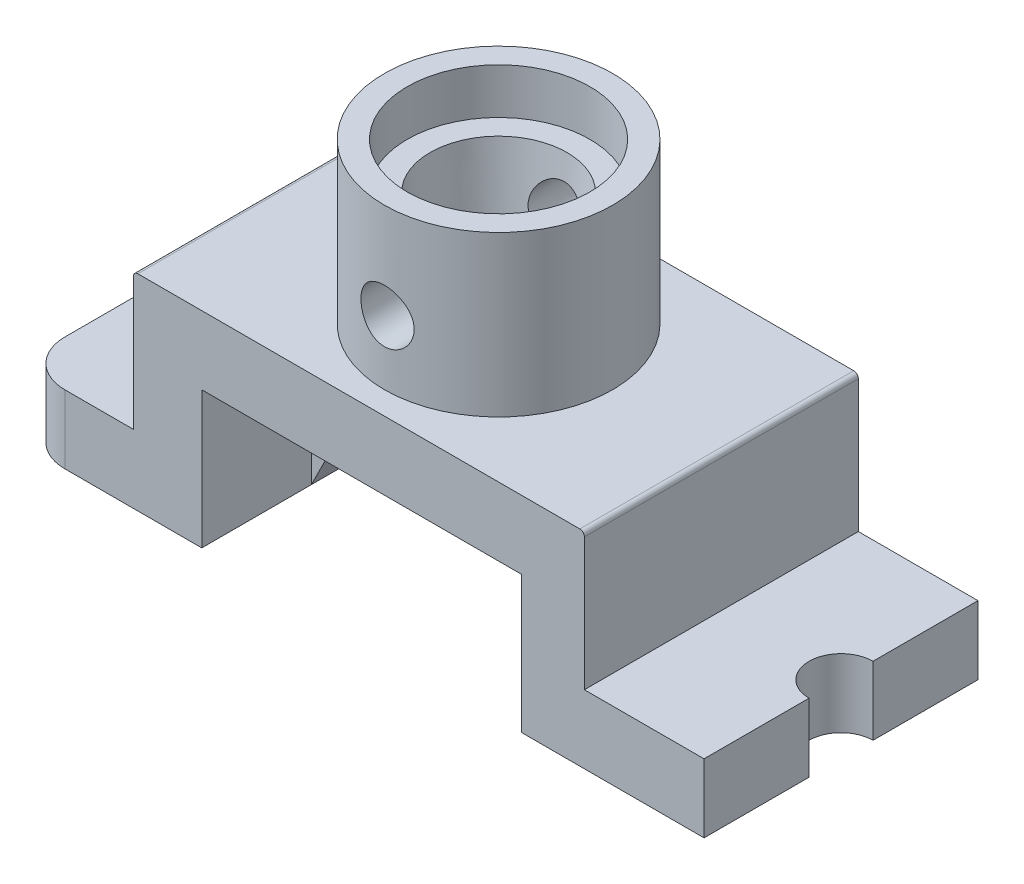
from build123d import *

# Parameters (mm, degrees)
BOSS_EXTRUDE1_DEPTH     = 600
SKETCH2_R               = 250
BOSS_EXTRUDE3_DEPTH     = 350
SKETCH6_R               = 200
CUT_EXTRUDE1_DEPTH      = 100
SKETCH8_R               = 100
SKETCH7_R               = 150
FILLET2_R               = 100
FILLET3_R               = 10
SKETCH11_R              = 58.235787107
CUT_EXTRUDE5_DEPTH      = 1362.628038628
CUT_EXTRUDE5_DEPTH_BACK = 1362.628038628
CUT_EXTRUDE6_REACH      = 1281.27
SKETCH12_R              = 70
RIB1_REACH              = 1260.583
SKETCH13_WALL_W         = 2854.575996278
SKETCH13_WALL_H         = 120
RIB2_REACH              = 1260.583
SKETCH14_WALL_W         = 2854.575996278
SKETCH14_WALL_H         = 120


with BuildPart() as part:
    # Sketch1 → Boss-Extrude1 (new body)
    with BuildSketch(Plane.XY):
        Polygon((-175.862068966, 0), (-575.862068966, 0), (-575.862068966, 150), (-325.862068966, 150), (-325.862068966, 450), (662.068965517, 450), (662.068965517, 150), (924.137931034, 150), (924.137931034, 0), (524.137931034, 0), (524.137931034, 300), (-175.862068966, 300), align=None)
    extrude(amount=BOSS_EXTRUDE1_DEPTH)

    # Sketch2 → Boss-Extrude3 (add)
    with BuildSketch(Plane(origin=(0, 450, 0), x_dir=(1, 0, 0), z_dir=(0, 1, 0))):
        with Locations(Location((174.137931034, -300, 0), (0, 0, 270))):
            Circle(SKETCH2_R)
    extrude(amount=BOSS_EXTRUDE3_DEPTH)

    # Sketch6 → Cut-Extrude1 (cut)
    with BuildSketch(Plane(origin=(0, 800, 0), x_dir=(1, 0, 0), z_dir=(0, 1, 0))):
        with Locations(Location((174.137931034, -300, 0), (0, 0, 270))):
            Circle(SKETCH6_R)
    extrude(amount=-CUT_EXTRUDE1_DEPTH, mode=Mode.SUBTRACT)

    # Sketch8 → Cut-Loft1 section 0
    with BuildSketch(Plane.XZ.offset(-300)):
        with Locations((174.137931034, 300)):
            Circle(SKETCH8_R)
    # Sketch7 → Cut-Loft1 section 1
    with BuildSketch(Plane(origin=(0, 700, 0), x_dir=(1, 0, 0), z_dir=(0, 1, 0))):
        with Locations((174.137931034, -300)):
            Circle(SKETCH7_R)
    loft(mode=Mode.SUBTRACT)

    # Fillet2
    fillet2_edges = [part.edges().sort_by_distance(p)[0] for p in [
        (-575.862068966, 75, 0),
        (-575.862068966, 75, 600),
    ]]
    fillet(fillet2_edges, radius=FILLET2_R)

    # Fillet3
    fillet3_edges = [part.edges().sort_by_distance(p)[0] for p in [
        (-325.862068966, 450, 300),
        (662.068965517, 450, 300),
    ]]
    fillet(fillet3_edges, radius=FILLET3_R)

    # Sketch11 → Cut-Extrude5 (cut, two sides)
    with BuildSketch(Plane.XY) as cut_extrude5_sk:
        with Locations(Location((174.137931034, 590, 0), (0, 0, 90.000000003))):
            Circle(SKETCH11_R)
    extrude(amount=CUT_EXTRUDE5_DEPTH, mode=Mode.SUBTRACT)
    extrude(cut_extrude5_sk.sketch, amount=-CUT_EXTRUDE5_DEPTH_BACK, mode=Mode.SUBTRACT)

    # Sketch12 → Cut-Extrude6 (cut, up to next)
    with BuildSketch(Plane(origin=(0, 150, 0), x_dir=(1, 0, 0), z_dir=(0, 1, 0)), mode=Mode.PRIVATE) as cut_extrude6_sk1:
        with Locations((924.137931034, -300)):
            Circle(SKETCH12_R)
    cut_extrude6_tool1 = extrude(cut_extrude6_sk1.sketch, amount=-CUT_EXTRUDE6_REACH, mode=Mode.PRIVATE) & part.part
    add(cut_extrude6_tool1.solids().sort_by_distance((924.137931, 150, 300))[0], mode=Mode.SUBTRACT)

    # Sketch13 wall → Rib1 (add, up to next)
    with BuildSketch(Plane(origin=(-100.862068966, 150, 300), x_dir=(0.4472135955, 0.894427191, 0), z_dir=(-0.894427191, 0.4472135955, 0)), mode=Mode.PRIVATE) as rib1_sk1:
        Rectangle(SKETCH13_WALL_W, SKETCH13_WALL_H)
    rib1_tool1 = extrude(rib1_sk1.sketch, amount=RIB1_REACH, mode=Mode.PRIVATE) - part.part
    add(rib1_tool1.solids().sort_by_distance((-100.862068966, 150, 300))[0])

    # Sketch14 wall → Rib2 (add, up to next)
    with BuildSketch(Plane(origin=(449.137931034, 150, 300), x_dir=(-0.4472135955, 0.894427191, 0), z_dir=(-0.894427191, -0.4472135955, 0)), mode=Mode.PRIVATE) as rib2_sk1:
        Rectangle(SKETCH14_WALL_W, SKETCH14_WALL_H)
    rib2_tool1 = extrude(rib2_sk1.sketch, amount=-RIB2_REACH, mode=Mode.PRIVATE) - part.part
    add(rib2_tool1.solids().sort_by_distance((449.137931034, 150, 300))[0])


solid = part.part
